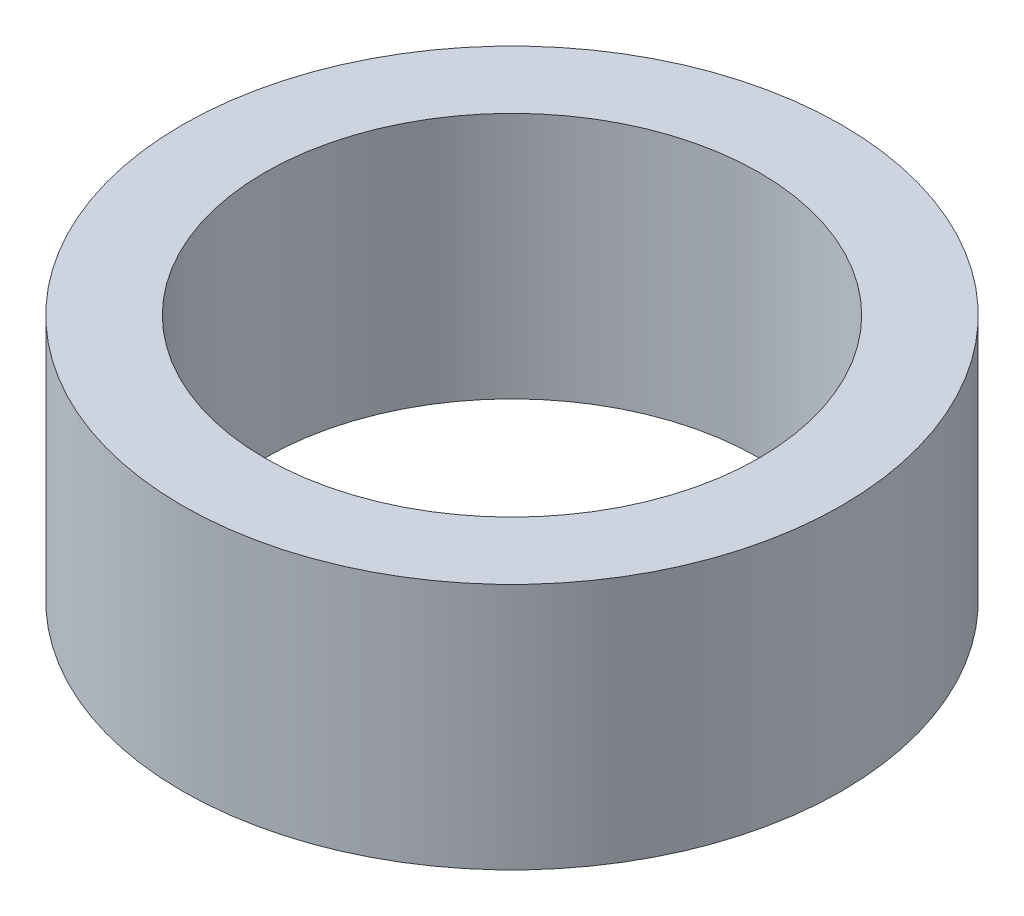
from build123d import *

# Parameters (mm, degrees)
ESQUISSE2_R        = 8
ESQUISSE2_R_2      = 6
BOSS_EXTRU_1_DEPTH = 6


with BuildPart() as part:
    # Esquisse2 → Boss.-Extru.1 (new body)
    with BuildSketch(Plane(origin=(0, 0, 0), x_dir=(1, 0, 0), z_dir=(0, 1, 0))):
        Circle(ESQUISSE2_R)
        Circle(ESQUISSE2_R_2, mode=Mode.SUBTRACT)
    extrude(amount=BOSS_EXTRU_1_DEPTH)


solid = part.part
